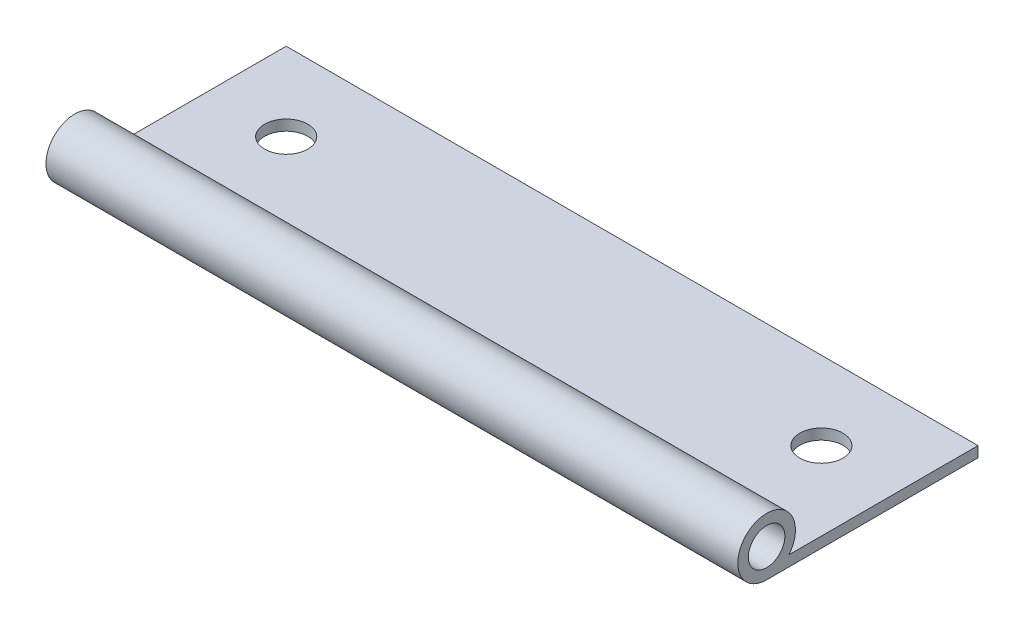
from build123d import *

# Parameters (mm, degrees)
SKETCH_1_R          = 1.9
EXTRUDE_1_DEPTH     = 72
SKETCH_2_R          = 2.25
CUT_EXTRUDE_1_DEPTH = 2.1


with BuildPart() as part:
    # 草图1 → 凸台-拉伸1 (new body)
    with BuildSketch(Plane(origin=(0, 0, 0), x_dir=(0, 0, -1), z_dir=(1, 0, 0))):
        with BuildLine():
            Line((0, 0), (19, 0))
            Line((19, 0), (19, -1.1))
            Line((19, -1.1), (0, -1.1))
            Line((0, -1.1), (-3, -1.1))
            ThreePointArc((-3, -1.1), (-4.284523258, 4.611088342), (-0.678362647, 0))
            Line((-0.678362647, 0), (0, 0))
        make_face()
        with Locations((-3, 1.9)):
            Circle(SKETCH_1_R, mode=Mode.SUBTRACT)
    extrude(amount=EXTRUDE_1_DEPTH)

    # 草图2 → 切除-拉伸1 (cut, through all)
    with BuildSketch(Plane(origin=(0, 0, 0), x_dir=(1, 0, 0), z_dir=(0, 1, 0))):
        with Locations((8.15, 10.85)):
            Circle(SKETCH_2_R)
        with Locations((63.85, 10.85)):
            Circle(SKETCH_2_R)
    extrude(amount=-CUT_EXTRUDE_1_DEPTH, mode=Mode.SUBTRACT)


solid = part.part
